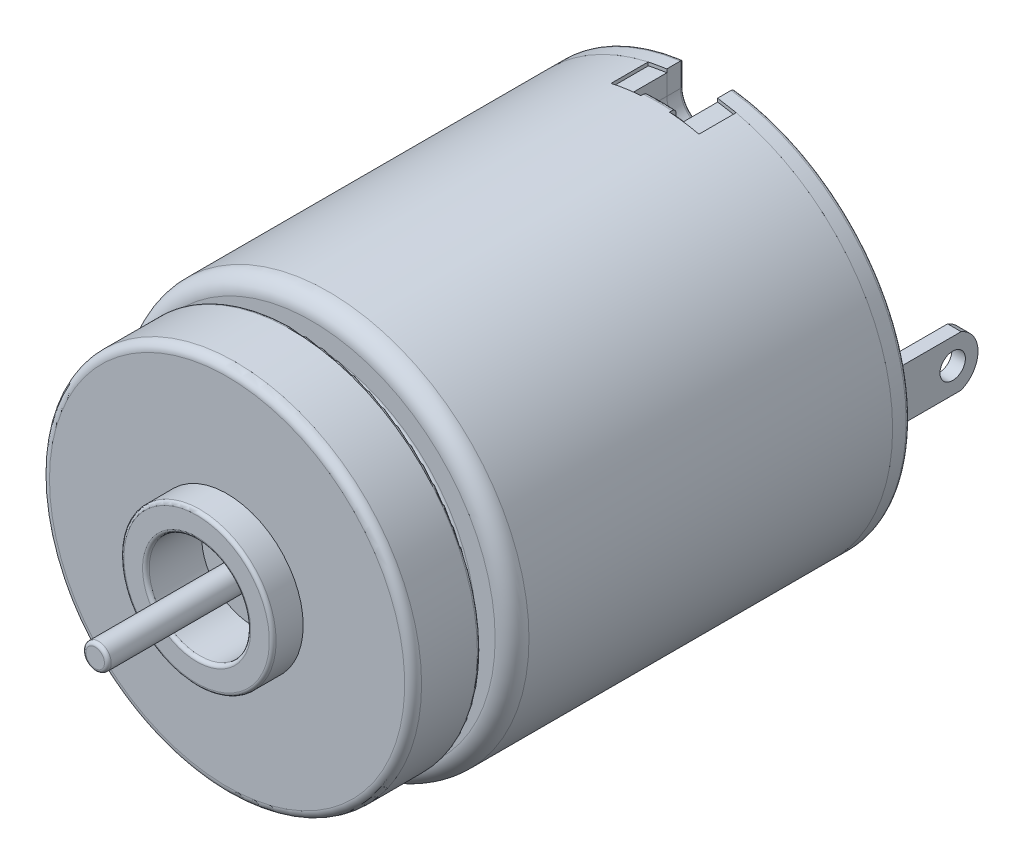
from build123d import *

# Parameters (mm, degrees)
SKETCH_1_R          = 11.85
EXTRUDE_1_DEPTH     = 22.5
SKETCH_2_R          = 9.5
EXTRUDE_2_DEPTH     = 3.5
SKETCH_4_R          = 0.75
EXTRUDE_3_DEPTH     = 9.3
SHELL_1_T           = -0.5
SKETCH_5_W          = 5.2
SKETCH_5_H          = 2.2
CUT_EXTRUDE_1_DEPTH = 15
SKETCH_6_R          = 11.85
EXTRUDE_4_DEPTH     = 1
SKETCH_7_W          = 3
SKETCH_7_H          = 3
CUT_EXTRUDE_2_DEPTH = 30
SKETCH_8_R          = 11.65
EXTRUDE_5_DEPTH     = 3
CUT_EXTRUDE_3_DEPTH = 3
CUT_EXTRUDE_4_DEPTH = 1
SKETCH_11_R         = 0.9
EXTRUDE_6_DEPTH     = 2
SKETCH_12_R         = 0.9
EXTRUDE_7_DEPTH     = 2.2
SKETCH_13_W         = 0.8
SKETCH_13_H         = 3
EXTRUDE_8_DEPTH     = 5.5
CUT_EXTRUDE_5_REACH = 45.377
SKETCH_15_R         = 1
CUT_EXTRUDE_6_DEPTH = 10
FILLET_1_R          = 0.5
FILLET_2_R          = 1
FILLET_3_R          = 0.2
FILLET_4_R          = 0.2
FILLET_5_R          = 0.2
FILLET_6_R          = 0.2
FILLET_7_R          = 0.2
FILLET_8_R          = 0.2
FILLET_9_R          = 0.2


with BuildPart() as part:
    # Sketch 1 → Extrude 1 (new body)
    with BuildSketch(Plane.XY):
        with Locations(Location((0, 0, 0), (0, 0, 180))):
            Circle(SKETCH_1_R)
    extrude(amount=EXTRUDE_1_DEPTH)

    # Sketch 2 → Extrude 2 (add)
    with BuildSketch(Plane.XY.offset(22.5)):
        Circle(SKETCH_2_R)
    extrude(amount=EXTRUDE_2_DEPTH)

    # Sketch 3 → Revolve 1 (revolve)
    with BuildSketch(Plane(origin=(0, 0, 0), x_dir=(1, 0, 0), z_dir=(0, 1, 0)), mode=Mode.PRIVATE) as revolve_1_sk:
        Polygon((-11, -23.5), (-11, -27.5), (-4.5, -27.5), (-4.5, -29.3), (-3, -29.3), (-3, -26), (-9.7, -26), (-9.7, -23.5), align=None)
    revolve(revolve_1_sk.sketch.rotate(Axis((0, 0, 28.5), (0, 0, -1)), 180), axis=Axis((0, 0, 28.5), (0, 0, -1)))

    # Sketch 4 → Extrude 3 (add)
    with BuildSketch(Plane.XY.offset(26)):
        with Locations(Location((0, 0, 0), (0, 0, 180))):
            Circle(SKETCH_4_R)
    extrude(amount=EXTRUDE_3_DEPTH)

    # Shell 1
    shell_1_openings = [part.faces().sort_by_distance(p)[0] for p in [
        (0, 0, 0),
    ]]
    offset(amount=SHELL_1_T, openings=shell_1_openings, kind=Kind.INTERSECTION)

    # Sketch 5 → Cut-Extrude 1 (cut, symmetric)
    with BuildSketch(Plane(origin=(0, 0, 0), x_dir=(1, 0, 0), z_dir=(0, 1, 0))):
        with Locations((0, -1.1)):
            Rectangle(SKETCH_5_W, SKETCH_5_H)
    extrude(amount=CUT_EXTRUDE_1_DEPTH, both=True, mode=Mode.SUBTRACT)

    # Sketch 7 → Cut-Extrude 2 (cut)
    with BuildSketch(Plane(origin=(0, 0, 0), x_dir=(0, 0, -1), z_dir=(1, 0, 0))):
        with Locations((-1.5, 0)):
            Rectangle(SKETCH_7_W, SKETCH_7_H)
    extrude(amount=-CUT_EXTRUDE_2_DEPTH, mode=Mode.SUBTRACT)

    # Fillet 1
    fillet_1_edges = [part.edges().sort_by_distance(p)[0] for p in [
        (-11, 0, 27.5),
    ]]
    fillet(fillet_1_edges, radius=FILLET_1_R)

    # Fillet 2
    fillet_2_edges = [part.edges().sort_by_distance(p)[0] for p in [
        (11.85, 0, 22.5),
    ]]
    fillet(fillet_2_edges, radius=FILLET_2_R)

    # Fillet 3
    fillet_3_edges = [part.edges().sort_by_distance(p)[0] for p in [
        (-9.5, 0, 22.5),
    ]]
    fillet(fillet_3_edges, radius=FILLET_3_R)

    # Fillet 4
    fillet_4_edges = [part.edges().sort_by_distance(p)[0] for p in [
        (-11, 0, 23.5),
    ]]
    fillet(fillet_4_edges, radius=FILLET_4_R)

    # Fillet 8
    fillet_8_edges = [part.edges().sort_by_distance(p)[0] for p in [
        (0.75, 0, 35.3),
    ]]
    fillet(fillet_8_edges, radius=FILLET_8_R)

    # Fillet 9
    fillet_9_edges = [part.edges().sort_by_distance(p)[0] for p in [
        (-4.5, 0, 29.3),
        (-3, 0, 29.3),
    ]]
    fillet(fillet_9_edges, radius=FILLET_9_R)



with BuildPart() as body_2:
    # Sketch 6 → Extrude 4 (new body)
    with BuildSketch(Plane.XY.offset(-1)):
        Circle(SKETCH_6_R)
    extrude(amount=EXTRUDE_4_DEPTH)


with BuildPart() as body_3:
    # Sketch 8 → Extrude 5 (new body)
    with BuildSketch(Plane.XY):
        Circle(SKETCH_8_R)
    extrude(amount=EXTRUDE_5_DEPTH)


with BuildPart() as cut_extrude_3_tool:
    # Sketch 9 → Cut-Extrude 3 (new body)
    with BuildSketch(Plane(origin=(0, 0, -1), x_dir=(-1, 0, 0), z_dir=(0, 0, -1))):
        with BuildLine():
            Line((-1.5, -13.35), (-1.5, -10.35))
            ThreePointArc((-1.5, -10.35), (0, -8.85), (1.5, -10.35))
            Line((1.5, -10.35), (1.5, -13.35))
            ThreePointArc((1.5, -13.35), (0, -14.85), (-1.5, -13.35))
        make_face()
        with BuildLine():
            Line((-1.5, 13.35), (-1.5, 10.35))
            ThreePointArc((-1.5, 10.35), (0, 8.85), (1.5, 10.35))
            Line((1.5, 10.35), (1.5, 13.35))
            ThreePointArc((1.5, 13.35), (0, 14.85), (-1.5, 13.35))
        make_face()
    extrude(amount=-CUT_EXTRUDE_3_DEPTH)


with BuildPart() as body_2_1:
    add(body_2.part)

    # Cut-Extrude 3: cut by cut_extrude_3_tool
    add(cut_extrude_3_tool.part, mode=Mode.SUBTRACT)

    # Sketch 10 → Cut-Extrude 4 (cut)
    with BuildSketch(Plane(origin=(0, 0, -1), x_dir=(-1, 0, 0), z_dir=(0, 0, -1))):
        with BuildLine():
            Line((-3.08474067, 5.342927568), (-3.337757481, 5.78116554))
            ThreePointArc((-3.337757481, 5.78116554), (-4.0174271, 6.263647866), (-4.826565534, 6.063560435))
            ThreePointArc((-4.826565534, 6.063560435), (-7.75, 0), (-4.826565534, -6.063560435))
            ThreePointArc((-4.826565534, -6.063560435), (-4.0174271, -6.263647866), (-3.337757481, -5.78116554))
            Line((-3.337757481, -5.78116554), (-3.08474067, -5.342927568))
            ThreePointArc((-3.08474067, -5.342927568), (-2.967183741, -4.662467616), (-3.318643502, -4.068059157))
            ThreePointArc((-3.318643502, -4.068059157), (-5.25, 0), (-3.318643502, 4.068059157))
            ThreePointArc((-3.318643502, 4.068059157), (-2.967183741, 4.662467616), (-3.08474067, 5.342927568))
        make_face()
        with BuildLine():
            Line((3.08474067, -5.342927568), (3.337757481, -5.78116554))
            ThreePointArc((3.337757481, -5.78116554), (4.0174271, -6.263647866), (4.826565534, -6.063560435))
            ThreePointArc((4.826565534, -6.063560435), (7.75, 0), (4.826565534, 6.063560435))
            ThreePointArc((4.826565534, 6.063560435), (4.0174271, 6.263647866), (3.337757481, 5.78116554))
            Line((3.337757481, 5.78116554), (3.08474067, 5.342927568))
            ThreePointArc((3.08474067, 5.342927568), (2.967183741, 4.662467616), (3.318643502, 4.068059157))
            ThreePointArc((3.318643502, 4.068059157), (5.25, 0), (3.318643502, -4.068059157))
            ThreePointArc((3.318643502, -4.068059157), (2.967183741, -4.662467616), (3.08474067, -5.342927568))
        make_face()
    extrude(amount=-CUT_EXTRUDE_4_DEPTH, mode=Mode.SUBTRACT)

    # Sketch 11 → Extrude 6 (add)
    with BuildSketch(Plane(origin=(0, 0, -1), x_dir=(-1, 0, 0), z_dir=(0, 0, -1))):
        with BuildLine():
            Line((-2, 3.75), (2, 3.75))
            ThreePointArc((2, 3.75), (0, -4.25), (-2, 3.75))
        make_face()
        Circle(SKETCH_11_R, mode=Mode.SUBTRACT)
    extrude(amount=EXTRUDE_6_DEPTH)

    # Sketch 13 → Extrude 8 (add)
    with BuildSketch(Plane(origin=(0, 0, -1), x_dir=(-1, 0, 0), z_dir=(0, 0, -1))):
        with Locations((-10, 0)):
            Rectangle(SKETCH_13_W, SKETCH_13_H)
        with Locations((10, 0)):
            Rectangle(SKETCH_13_W, SKETCH_13_H)
    extrude(amount=EXTRUDE_8_DEPTH)

    # Cut-Extrude 5: up to this face of the body (flat: up to its plane)
    cut_extrude_5_end = Plane(body_2_1.part.faces().sort_by_distance((-10.4, 0, -3.75))[0])
    # Sketch 14 → Cut-Extrude 5 (cut, up to the picked face)
    with BuildSketch(Plane(origin=(10.4, 0, 0), x_dir=(0, 0, -1), z_dir=(1, 0, 0)), mode=Mode.PRIVATE) as cut_extrude_5_sk1:
        with BuildLine():
            Line((6.5, 0), (6.5, 1.5))
            Line((6.5, 1.5), (5.5, 1.5))
            ThreePointArc((5.5, 1.5), (6.227081728, 0.901387819), (6.5, 0))
        make_face()
    cut_extrude_5_tool1 = split(extrude(cut_extrude_5_sk1.sketch, amount=-CUT_EXTRUDE_5_REACH, mode=Mode.PRIVATE), bisect_by=cut_extrude_5_end, keep=Keep.BOTH, mode=Mode.PRIVATE)
    # Sketch 14 → Cut-Extrude 5 (cut, up to the picked face)
    with BuildSketch(Plane(origin=(10.4, 0, 0), x_dir=(0, 0, -1), z_dir=(1, 0, 0)), mode=Mode.PRIVATE) as cut_extrude_5_sk2:
        with BuildLine():
            Line((6.5, -1.5), (6.5, 0))
            ThreePointArc((6.5, 0), (6.227081728, -0.901387819), (5.5, -1.5))
            Line((5.5, -1.5), (6.5, -1.5))
        make_face()
    cut_extrude_5_tool2 = split(extrude(cut_extrude_5_sk2.sketch, amount=-CUT_EXTRUDE_5_REACH, mode=Mode.PRIVATE), bisect_by=cut_extrude_5_end, keep=Keep.BOTH, mode=Mode.PRIVATE)
    # Sketch 14 → Cut-Extrude 5 (cut, up to the picked face)
    with BuildSketch(Plane(origin=(10.4, 0, 0), x_dir=(0, 0, -1), z_dir=(1, 0, 0)), mode=Mode.PRIVATE) as cut_extrude_5_sk3:
        with BuildLine():
            ThreePointArc((5.75, 0), (5.684653197, 0.306186218), (5.5, 0.559016994))
            Line((5.5, 0.559016994), (5.5, -0.559016994))
            ThreePointArc((5.5, -0.559016994), (5.684653197, -0.306186218), (5.75, 0))
        make_face()
    cut_extrude_5_tool3 = split(extrude(cut_extrude_5_sk3.sketch, amount=-CUT_EXTRUDE_5_REACH, mode=Mode.PRIVATE), bisect_by=cut_extrude_5_end, keep=Keep.BOTH, mode=Mode.PRIVATE)
    # Sketch 14 → Cut-Extrude 5 (cut, up to the picked face)
    with BuildSketch(Plane(origin=(10.4, 0, 0), x_dir=(0, 0, -1), z_dir=(1, 0, 0)), mode=Mode.PRIVATE) as cut_extrude_5_sk4:
        with BuildLine():
            Line((5.5, -0.559016994), (5.5, 0.559016994))
            ThreePointArc((5.5, 0.559016994), (4.25, 0), (5.5, -0.559016994))
        make_face()
    cut_extrude_5_tool4 = split(extrude(cut_extrude_5_sk4.sketch, amount=-CUT_EXTRUDE_5_REACH, mode=Mode.PRIVATE), bisect_by=cut_extrude_5_end, keep=Keep.BOTH, mode=Mode.PRIVATE)
    add(cut_extrude_5_tool1.solids().sort_by(Axis((10.4, 1.151689, -6.226983), (-1, 0, 0)))[0], mode=Mode.SUBTRACT)
    add(cut_extrude_5_tool2.solids().sort_by(Axis((10.4, -1.151689, -6.226983), (-1, 0, 0)))[0], mode=Mode.SUBTRACT)
    add(cut_extrude_5_tool3.solids().sort_by(Axis((10.4, 0, -5.601582), (-1, 0, 0)))[0], mode=Mode.SUBTRACT)
    add(cut_extrude_5_tool4.solids().sort_by(Axis((10.4, 0, -4.925988), (-1, 0, 0)))[0], mode=Mode.SUBTRACT)


with BuildPart() as body_3_1:
    add(body_3.part)

    # Cut-Extrude 3: cut by cut_extrude_3_tool
    add(cut_extrude_3_tool.part, mode=Mode.SUBTRACT)


with BuildPart() as body_4:
    # Sketch 12 → Extrude 7 (new body)
    with BuildSketch(Plane(origin=(0, 0, -1), x_dir=(-1, 0, 0), z_dir=(0, 0, -1))):
        Circle(SKETCH_12_R)
    extrude(amount=EXTRUDE_7_DEPTH)

    # Fillet 7
    fillet_7_edges = [body_4.edges().sort_by_distance(p)[0] for p in [
        (0.9, 0, -3.2),
    ]]
    fillet(fillet_7_edges, radius=FILLET_7_R)


with BuildPart() as cut_extrude_6_tool:
    # Sketch 15 → Cut-Extrude 6 (new body)
    with BuildSketch(Plane(origin=(0, 0, -1), x_dir=(-1, 0, 0), z_dir=(0, 0, -1))):
        with Locations((0, 6.5)):
            Circle(SKETCH_15_R)
        with Locations(Location((0, -6.5, 0), (0, 0, 180))):
            Circle(SKETCH_15_R)
    extrude(amount=-CUT_EXTRUDE_6_DEPTH)


with BuildPart() as body_2_2:
    add(body_2_1.part)

    # Cut-Extrude 6: cut by cut_extrude_6_tool
    add(cut_extrude_6_tool.part, mode=Mode.SUBTRACT)

    # Fillet 5
    fillet_5_edges = [body_2_2.edges().sort_by_distance(p)[0] for p in [
        (1.5, -11.05233996, -1),
        (-1.5, -11.05233996, -1),
        (0, -8.85, -1),
        (1.5, 11.05233996, -1),
        (0, 8.85, -1),
        (-1.5, 11.05233996, -1),
        (-11.85, 0, -1),
        (11.85, 0, -1),
    ]]
    fillet(fillet_5_edges, radius=FILLET_5_R)

    # Fillet 6
    fillet_6_edges = [body_2_2.edges().sort_by_distance(p)[0] for p in [
        (0, -4.25, -3),
    ]]
    fillet(fillet_6_edges, radius=FILLET_6_R)


with BuildPart() as body_3_2:
    add(body_3_1.part)

    # Cut-Extrude 6: cut by cut_extrude_6_tool
    add(cut_extrude_6_tool.part, mode=Mode.SUBTRACT)


with BuildPart() as part_1:
    add(part.part)

    add(body_3_2.part)  # Sweep 4 merges body 3
    # Sweep 4: sweep along a path in Sketch 17
    with BuildLine(Plane(origin=(0, 0, 2.2), x_dir=(-1, 0, 0), z_dir=(0, 0, -1))) as sweep_4_path:
        ThreePointArc((0.826614214, -11.821133996), (-0.014761079, -11.849990806), (-0.856061869, -11.819037951))
    # Sketch 18 → Sweep 4 (sweep)
    with BuildSketch(Plane(origin=(0, 0, 0), x_dir=(0, 0, -1), z_dir=(0.9975640502598243, -0.06975647374412547, 0))):
        with BuildLine():
            Line((-1.647377668, -10.350601931), (-1.84735438, -10.353653925))
            Line((-1.84735438, -10.353653925), (-1.995748302, -11.602642179))
            add(Edge.make_bspline(
                [(-2.048546123, -11.65048719), (-2.00143283, -11.65048719), (-1.995748302, -11.602642179)],
                knots=[2.585092677, 2.585092677, 2.585092677, 3.782431299, 3.782431299, 3.782431299], degree=2, weights=[1, 0.826086248, 1]))
            Line((-2.048546123, -11.65048719), (-2.2, -11.65048719))
            Line((-2.2, -11.65048719), (-2.2, -11.85))
            Line((-2.2, -11.85), (-2.060652408, -11.85))
            add(Edge.make_bspline(
                [(-2.060652408, -11.85), (-1.82926275, -11.847414963), (-1.801609774, -11.616990332)],
                knots=[0.01098888, 0.01098888, 0.01098888, 1.450858792, 1.450858792, 1.450858792], degree=2, weights=[1, 0.751848617, 1]))
            Line((-1.801609774, -11.616990332), (-1.647377668, -10.350601931))
        make_face()
    sweep_4 = sweep(path=sweep_4_path.line)

    # Mirror 1: Sweep 4 across plane
    add(sweep_4.mirror(Plane.ZX))


solid = Compound([body_4.part, body_2_2.part, part_1.part])
